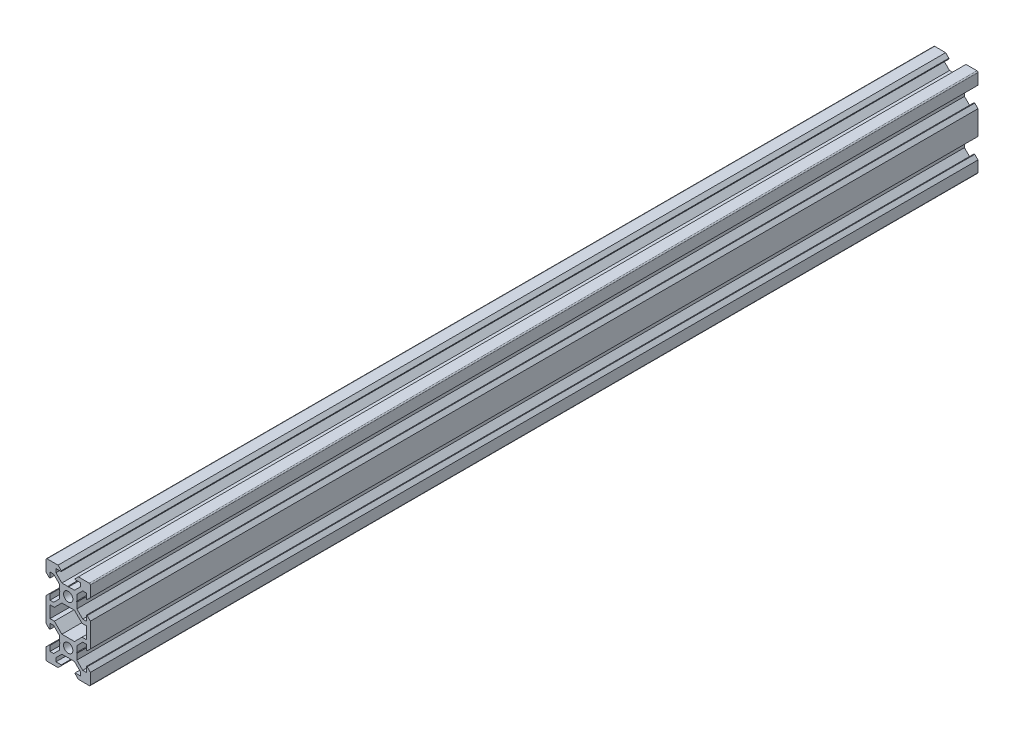
from build123d import *

# Parameters (mm, degrees)
SKETCH1_R          = 2.1
EXTRUDE_2481_DEPTH = 400


with BuildPart() as part:
    # Sketch1 → Extrude 2481 (new body)
    with BuildSketch(Plane.XY):
        with BuildLine():
            Line((4.58, -20), (9.5, -20))
            ThreePointArc((9.5, -20), (9.853553391, -19.853553391), (10, -19.5))
            Line((10, -19.5), (10, -14.58))
            Line((10, -14.58), (8.545, -13.125))
            Line((8.545, -13.125), (8.2, -13.125))
            Line((8.2, -13.125), (8.2, -15.5))
            Line((8.2, -15.5), (6.560660172, -15.5))
            Line((6.560660172, -15.5), (3.9, -12.839339828))
            Line((3.9, -12.839339828), (3.9, -10.21))
            Line((3.9, -10.21), (3.69, -10))
            Line((3.69, -10), (3.9, -9.79))
            Line((3.9, -9.79), (3.9, -7.160660172))
            Line((3.9, -7.160660172), (6.560660172, -4.5))
            Line((6.560660172, -4.5), (8.2, -4.5))
            Line((8.2, -4.5), (8.2, -6.875))
            Line((8.2, -6.875), (8.545, -6.875))
            Line((8.545, -6.875), (10, -5.42))
            Line((10, -5.42), (10, 5.42))
            Line((10, 5.42), (8.545, 6.875))
            Line((8.545, 6.875), (8.2, 6.875))
            Line((8.2, 6.875), (8.2, 4.5))
            Line((8.2, 4.5), (6.560660172, 4.5))
            Line((6.560660172, 4.5), (3.9, 7.160660172))
            Line((3.9, 7.160660172), (3.9, 9.79))
            Line((3.9, 9.79), (3.69, 10))
            Line((3.69, 10), (3.9, 10.21))
            Line((3.9, 10.21), (3.9, 12.839339828))
            Line((3.9, 12.839339828), (6.560660172, 15.5))
            Line((6.560660172, 15.5), (8.2, 15.5))
            Line((8.2, 15.5), (8.2, 13.125))
            Line((8.2, 13.125), (8.545, 13.125))
            Line((8.545, 13.125), (10, 14.58))
            Line((10, 14.58), (10, 19.5))
            ThreePointArc((10, 19.5), (9.853553391, 19.853553391), (9.5, 20))
            Line((9.5, 20), (4.58, 20))
            Line((4.58, 20), (3.125, 18.545))
            Line((3.125, 18.545), (3.125, 18.2))
            Line((3.125, 18.2), (5.5, 18.2))
            Line((5.5, 18.2), (5.5, 16.560660172))
            Line((5.5, 16.560660172), (2.839339828, 13.9))
            Line((2.839339828, 13.9), (0.21, 13.9))
            Line((0.21, 13.9), (0, 13.69))
            Line((0, 13.69), (-0.21, 13.9))
            Line((-0.21, 13.9), (-2.839339828, 13.9))
            Line((-2.839339828, 13.9), (-5.5, 16.560660172))
            Line((-5.5, 16.560660172), (-5.5, 18.2))
            Line((-5.5, 18.2), (-3.125, 18.2))
            Line((-3.125, 18.2), (-3.125, 18.545))
            Line((-3.125, 18.545), (-4.58, 20))
            Line((-4.58, 20), (-9.5, 20))
            ThreePointArc((-9.5, 20), (-9.853553391, 19.853553391), (-10, 19.5))
            Line((-10, 19.5), (-10, 14.58))
            Line((-10, 14.58), (-8.545, 13.125))
            Line((-8.545, 13.125), (-8.2, 13.125))
            Line((-8.2, 13.125), (-8.2, 15.5))
            Line((-8.2, 15.5), (-6.560660172, 15.5))
            Line((-6.560660172, 15.5), (-3.9, 12.839339828))
            Line((-3.9, 12.839339828), (-3.9, 10.21))
            Line((-3.9, 10.21), (-3.69, 10))
            Line((-3.69, 10), (-3.9, 9.79))
            Line((-3.9, 9.79), (-3.9, 7.160660172))
            Line((-3.9, 7.160660172), (-6.560660172, 4.5))
            Line((-6.560660172, 4.5), (-8.2, 4.5))
            Line((-8.2, 4.5), (-8.2, 6.875))
            Line((-8.2, 6.875), (-8.545, 6.875))
            Line((-8.545, 6.875), (-10, 5.42))
            Line((-10, 5.42), (-10, -5.42))
            Line((-10, -5.42), (-8.545, -6.875))
            Line((-8.545, -6.875), (-8.2, -6.875))
            Line((-8.2, -6.875), (-8.2, -4.5))
            Line((-8.2, -4.5), (-6.560660172, -4.5))
            Line((-6.560660172, -4.5), (-3.9, -7.160660172))
            Line((-3.9, -7.160660172), (-3.9, -9.79))
            Line((-3.9, -9.79), (-3.69, -10))
            Line((-3.69, -10), (-3.9, -10.21))
            Line((-3.9, -10.21), (-3.9, -12.839339828))
            Line((-3.9, -12.839339828), (-6.560660172, -15.5))
            Line((-6.560660172, -15.5), (-8.2, -15.5))
            Line((-8.2, -15.5), (-8.2, -13.125))
            Line((-8.2, -13.125), (-8.545, -13.125))
            Line((-8.545, -13.125), (-10, -14.58))
            Line((-10, -14.58), (-10, -19.5))
            ThreePointArc((-10, -19.5), (-9.853553391, -19.853553391), (-9.5, -20))
            Line((-9.5, -20), (-4.58, -20))
            Line((-4.58, -20), (-3.125, -18.545))
            Line((-3.125, -18.545), (-3.125, -18.2))
            Line((-3.125, -18.2), (-5.5, -18.2))
            Line((-5.5, -18.2), (-5.5, -16.560660172))
            Line((-5.5, -16.560660172), (-2.839339828, -13.9))
            Line((-2.839339828, -13.9), (-0.21, -13.9))
            Line((-0.21, -13.9), (0, -13.69))
            Line((0, -13.69), (0.21, -13.9))
            Line((0.21, -13.9), (2.839339828, -13.9))
            Line((2.839339828, -13.9), (5.5, -16.560660172))
            Line((5.5, -16.560660172), (5.5, -18.2))
            Line((5.5, -18.2), (3.125, -18.2))
            Line((3.125, -18.2), (3.125, -18.545))
            Line((3.125, -18.545), (4.58, -20))
        make_face()
        with Locations((0, -10)):
            Circle(SKETCH1_R, mode=Mode.SUBTRACT)
        Polygon((-6.239339828, -2.7), (-8.2, -2.7), (-8.2, 2.7), (-6.239339828, 2.7), (-2.839339828, 6.1), (2.839339828, 6.1), (6.239339828, 2.7), (8.2, 2.7), (8.2, -2.7), (6.239339828, -2.7), (2.839339828, -6.1), (-2.839339828, -6.1), align=None, mode=Mode.SUBTRACT)
        with Locations((0, 10)):
            Circle(SKETCH1_R, mode=Mode.SUBTRACT)
    extrude(amount=EXTRUDE_2481_DEPTH)


solid = part.part
